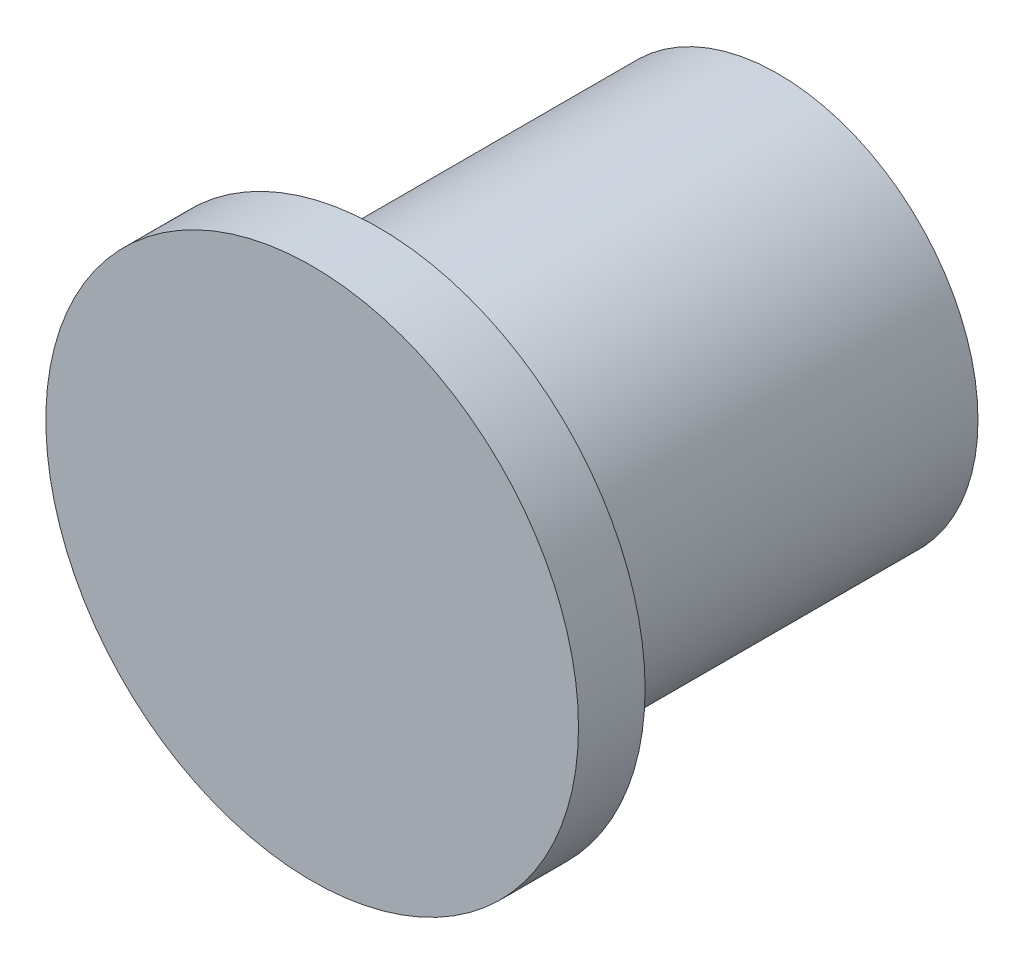
from build123d import *

# Parameters (mm, degrees)
SKETCH1_R           = 76.2
BOSS_EXTRUDE1_DEPTH = 152.4
SKETCH2_R           = 101.6
BOSS_EXTRUDE2_DEPTH = 25.4


with BuildPart() as part:
    # Sketch1 → Boss-Extrude1 (new body)
    with BuildSketch(Plane.XY):
        Circle(SKETCH1_R)
    extrude(amount=BOSS_EXTRUDE1_DEPTH)

    # Sketch2 → Boss-Extrude2 (add)
    with BuildSketch(Plane.XY.offset(152.4)):
        Circle(SKETCH2_R)
    extrude(amount=BOSS_EXTRUDE2_DEPTH)


solid = part.part
